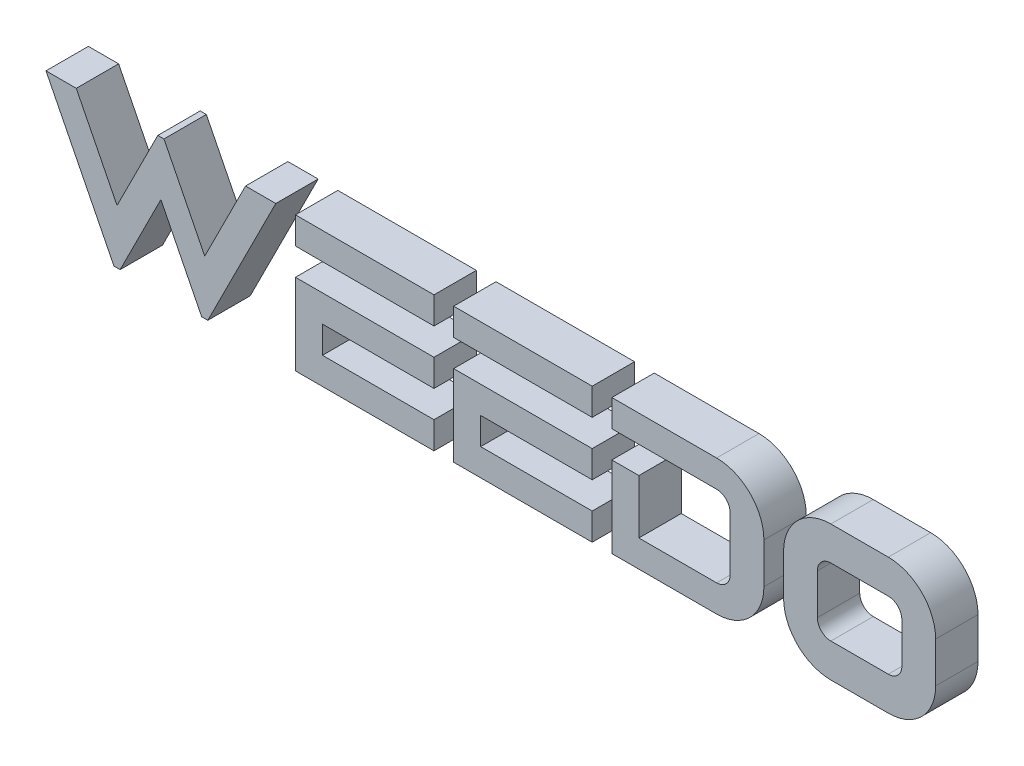
from build123d import *

# Parameters (mm, degrees)
EXTRUDE_1_DEPTH   = 4
EXTRUDE_1_2_DEPTH = 4
EXTRUDE_1_3_DEPTH = 4
SKETCH_1_W        = 13.079
SKETCH_1_H        = 2.552
EXTRUDE_1_4_DEPTH = 4
EXTRUDE_1_5_DEPTH = 4
EXTRUDE_1_6_DEPTH = 4
EXTRUDE_1_7_DEPTH = 4


with BuildPart() as part:
    # 草图1 → 凸台-拉伸1 (new body)
    with BuildSketch(Plane.XY):
        Polygon((-50.96092739, 11.126463695), (-57.377233738, -1.633536305), (-57.957143582, -1.633536305), (-61.80692739, 6.022463695), (-65.656711199, -1.633536305), (-66.236621043, -1.633536305), (-72.65292739, 11.126463695), (-69.796449929, 11.126463695), (-65.946666121, 3.470463695), (-62.096882313, 11.126463695), (-61.516972468, 11.126463695), (-57.66718866, 3.470463695), (-53.817404851, 11.126463695), align=None)
    extrude(amount=EXTRUDE_1_DEPTH)


with BuildPart() as body_2:
    # 草图1 → Extrude 1 2 (new body)
    with BuildSketch(Plane.XY):
        with BuildLine():
            Line((-19.23492739, 11.126463695), (-9.34592739, 11.126463695))
            ThreePointArc((-9.34592739, 11.126463695), (-6.187988506, 9.81840258), (-4.87992739, 6.660463695))
            Line((-4.87992739, 6.660463695), (-4.87992739, 2.832463695))
            ThreePointArc((-4.87992739, 2.832463695), (-6.187988506, -0.32547519), (-9.34592739, -1.633536305))
            Line((-9.34592739, -1.633536305), (-19.23492739, -1.633536305))
            Line((-19.23492739, -1.633536305), (-19.23492739, 6.022463695))
            Line((-19.23492739, 6.022463695), (-16.68292739, 6.022463695))
            Line((-16.68292739, 6.022463695), (-16.68292739, 0.918463695))
            Line((-16.68292739, 0.918463695), (-9.34592739, 0.918463695))
            ThreePointArc((-9.34592739, 0.918463695), (-8.443659138, 1.292195442), (-8.06992739, 2.194463695))
            Line((-8.06992739, 2.194463695), (-8.06992739, 7.298463695))
            ThreePointArc((-8.06992739, 7.298463695), (-8.443659138, 8.200731948), (-9.34592739, 8.574463695))
            Line((-9.34592739, 8.574463695), (-19.23492739, 8.574463695))
            Line((-19.23492739, 8.574463695), (-19.23492739, 11.126463695))
        make_face()
    extrude(amount=EXTRUDE_1_2_DEPTH)


with BuildPart() as body_3:
    # 草图1 → Extrude 1 3 (new body)
    with BuildSketch(Plane.XY):
        Polygon((-21.09092739, -1.633536305), (-34.16992739, -1.633536305), (-34.16992739, 6.022463695), (-21.09092739, 6.022463695), (-21.09092739, 3.470463695), (-31.61792739, 3.470463695), (-31.61792739, 0.918463695), (-21.09092739, 0.918463695), align=None)
    extrude(amount=EXTRUDE_1_3_DEPTH)


with BuildPart() as body_4:
    # 草图1 → Extrude 1 4 (new body)
    with BuildSketch(Plane.XY):
        with Locations((-42.56542739, 9.850463695)):
            Rectangle(SKETCH_1_W, SKETCH_1_H)
    extrude(amount=EXTRUDE_1_4_DEPTH)


with BuildPart() as body_5:
    # 草图1 → Extrude 1 5 (new body)
    with BuildSketch(Plane.XY):
        Polygon((-36.02592739, 3.470463695), (-46.55292739, 3.470463695), (-46.55292739, 0.918463695), (-36.02592739, 0.918463695), (-36.02592739, -1.633536305), (-49.10492739, -1.633536305), (-49.10492739, 6.022463695), (-36.02592739, 6.022463695), align=None)
    extrude(amount=EXTRUDE_1_5_DEPTH)


with BuildPart() as body_6:
    # 草图1 → Extrude 1 6 (new body)
    with BuildSketch(Plane.XY):
        with Locations((-27.63042739, 9.850463695)):
            Rectangle(SKETCH_1_W, SKETCH_1_H)
    extrude(amount=EXTRUDE_1_6_DEPTH)


with BuildPart() as body_7:
    # 草图1 → Extrude 1 7 (new body)
    with BuildSketch(Plane.XY):
        with BuildLine():
            Line((-3.02392739, 2.832463695), (-3.02392739, 6.660463695))
            ThreePointArc((-3.02392739, 6.660463695), (-1.715866275, 9.81840258), (1.44207261, 11.126463695))
            Line((1.44207261, 11.126463695), (6.86507261, 11.126463695))
            ThreePointArc((6.86507261, 11.126463695), (10.023011494, 9.81840258), (11.33107261, 6.660463695))
            Line((11.33107261, 6.660463695), (11.33107261, 2.832463695))
            ThreePointArc((11.33107261, 2.832463695), (10.023011494, -0.32547519), (6.86507261, -1.633536305))
            Line((6.86507261, -1.633536305), (1.44207261, -1.633536305))
            ThreePointArc((1.44207261, -1.633536305), (-1.715866275, -0.32547519), (-3.02392739, 2.832463695))
        make_face()
        with BuildLine():
            Line((1.44207261, 1.556463695), (6.86507261, 1.556463695))
            ThreePointArc((6.86507261, 1.556463695), (7.767340862, 1.930195442), (8.14107261, 2.832463695))
            Line((8.14107261, 2.832463695), (8.14107261, 6.660463695))
            ThreePointArc((8.14107261, 6.660463695), (7.767340862, 7.562731948), (6.86507261, 7.936463695))
            Line((6.86507261, 7.936463695), (1.44207261, 7.936463695))
            ThreePointArc((1.44207261, 7.936463695), (0.539804357, 7.562731948), (0.16607261, 6.660463695))
            Line((0.16607261, 6.660463695), (0.16607261, 2.832463695))
            ThreePointArc((0.16607261, 2.832463695), (0.539804357, 1.930195442), (1.44207261, 1.556463695))
        make_face(mode=Mode.SUBTRACT)
    extrude(amount=EXTRUDE_1_7_DEPTH)


solid = Compound([part.part, body_2.part, body_3.part, body_4.part, body_5.part, body_6.part, body_7.part])
